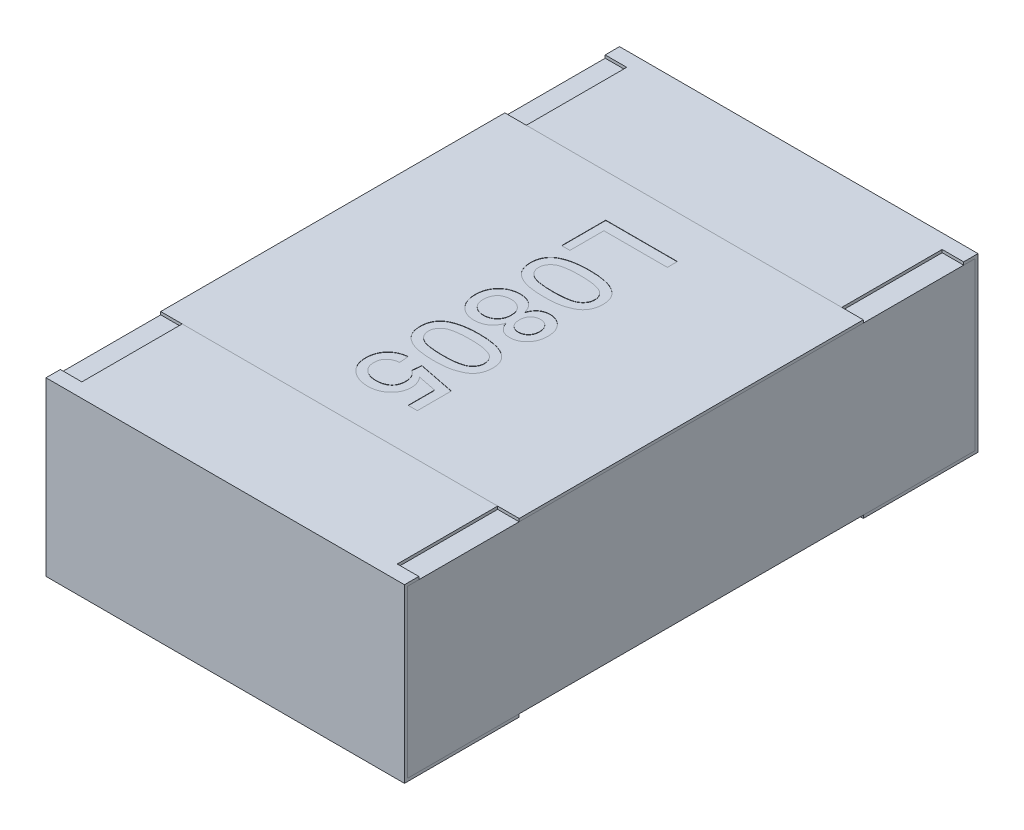
from build123d import *

# Parameters (mm, degrees)
BOSS_EXTRUDE2_DEPTH   = 0.625
BOSS_EXTRUDE2_2_DEPTH = 0.625
BOSS_EXTRUDE3_START   = -0.625
SKETCH5_W             = 1.98
SKETCH5_H             = 0.58
BOSS_EXTRUDE3_DEPTH   = 1.25
SKETCH6_W             = 0.075
SKETCH6_H             = 0.35
CUT_EXTRUDE1_DEPTH    = 0.01
SKETCH7_W             = 1.25
SKETCH7_H             = 1.2
BOSS_EXTRUDE4_DEPTH   = 0.01
TEXT0805_DEPTH        = 0.001


with BuildPart() as part:
    # Sketch4 → Boss-Extrude2 (new body, symmetric)
    with BuildSketch(Plane(origin=(0, 0, 0), x_dir=(0, 0, -1), z_dir=(1, 0, 0))):
        Polygon((-1, 0.3), (-1, -0.3), (-0.6, -0.3), (-0.6, -0.29), (-0.99, -0.29), (-0.99, 0.29), (-0.6, 0.29), (-0.6, 0.3), align=None)
    extrude(amount=BOSS_EXTRUDE2_DEPTH, both=True)


with BuildPart() as body_2:
    # Sketch4 → Boss-Extrude2 2 (new body, symmetric)
    with BuildSketch(Plane(origin=(0, 0, 0), x_dir=(0, 0, -1), z_dir=(1, 0, 0))):
        Polygon((0.6, 0.3), (1, 0.3), (1, -0.3), (0.6, -0.3), (0.6, -0.29), (0.99, -0.29), (0.99, 0.29), (0.6, 0.29), align=None)
    extrude(amount=BOSS_EXTRUDE2_2_DEPTH, both=True)


with BuildPart() as body_3:
    # Sketch5 → Boss-Extrude3 (new body)
    with BuildSketch(Plane(origin=(0, 0, 0), x_dir=(0, 0, -1), z_dir=(1, 0, 0)).offset(BOSS_EXTRUDE3_START)):
        Rectangle(SKETCH5_W, SKETCH5_H)
    extrude(amount=BOSS_EXTRUDE3_DEPTH)


with BuildPart() as cut_extrude1_tool:
    # Sketch6 → Cut-Extrude1 (new body)
    with BuildSketch(Plane(origin=(0, 0.3, 0), x_dir=(1, 0, 0), z_dir=(0, 1, 0))):
        with Locations((-0.5875, 0.775)):
            Rectangle(SKETCH6_W, SKETCH6_H)
        with Locations((0.5875, 0.775)):
            Rectangle(SKETCH6_W, SKETCH6_H)
        with Locations((0.5875, -0.775)):
            Rectangle(SKETCH6_W, SKETCH6_H)
        with Locations((-0.5875, -0.775)):
            Rectangle(SKETCH6_W, SKETCH6_H)
    extrude(amount=-CUT_EXTRUDE1_DEPTH)


with BuildPart() as part_1:
    add(part.part)

    # Cut-Extrude1: cut by cut_extrude1_tool
    add(cut_extrude1_tool.part, mode=Mode.SUBTRACT)


with BuildPart() as body_2_1:
    add(body_2.part)

    # Cut-Extrude1: cut by cut_extrude1_tool
    add(cut_extrude1_tool.part, mode=Mode.SUBTRACT)


with BuildPart() as body_4:
    # Sketch7 → Boss-Extrude4 (new body)
    with BuildSketch(Plane(origin=(0, 0.29, 0), x_dir=(1, 0, 0), z_dir=(0, 1, 0))):
        Rectangle(SKETCH7_W, SKETCH7_H)
    extrude(amount=BOSS_EXTRUDE4_DEPTH)

    # Sketch11 → TEXT0805 (cut)
    with BuildSketch(Plane(origin=(0, 0.3, 0), x_dir=(1, 0, 0), z_dir=(0, 1, 0))):
        Polygon((-0.125, 0.451923077), (0.125, 0.451923077), (0.125, 0.416666667), (-0.096153846, 0.416666667), (-0.096153846, 0.298076923), (-0.125, 0.298076923), align=None)
        with BuildLine():
            add(Edge.make_bspline(
                [(-0.001702724, 0.272435897), (0.001870005, 0.272403606), (0.008867478, 0.27234036), (0.019106037, 0.271948067), (0.028829172, 0.271263154), (0.038028443, 0.270240773), (0.0467246, 0.269030064), (0.05490528, 0.267456198), (0.062588678, 0.265685164), (0.069767331, 0.263560961), (0.076501073, 0.261224714), (0.082785669, 0.25858275), (0.088583945, 0.255584058), (0.094053366, 0.252499041), (0.098937729, 0.248907292), (0.103546409, 0.245264826), (0.107616333, 0.241199109), (0.111280719, 0.236903509), (0.114513306, 0.232306834), (0.117302904, 0.227435485), (0.119765846, 0.222307654), (0.121619965, 0.216825758), (0.12313146, 0.211103562), (0.124243336, 0.205097029), (0.124898824, 0.198799537), (0.124965894, 0.194496087), (0.125, 0.192307692)],
                knots=[0, 0, 0, 0, 1.0718e-05, 2.0992e-05, 3.0733e-05, 3.9952e-05, 4.8756e-05, 5.7065e-05, 6.4937e-05, 7.2401e-05, 7.9512e-05, 8.6312e-05, 9.2829e-05, 9.9091e-05, 0.000105122, 0.000110996, 0.000116698, 0.000122347, 0.000127918, 0.000133528, 0.000139173, 0.000144954, 0.000150858, 0.000156918, 0.000163262, 0.000169825, 0.000169825, 0.000169825, 0.000169825], degree=3))
            add(Edge.make_bspline(
                [(0.125, 0.192307692), (0.124905525, 0.18909709), (0.124719924, 0.182789734), (0.123208745, 0.173579982), (0.120617247, 0.164904112), (0.11714849, 0.156763482), (0.11266138, 0.149334117), (0.107346921, 0.142617281), (0.100982609, 0.136884361), (0.0937773, 0.131945986), (0.08571669, 0.12771133), (0.076876688, 0.123923256), (0.067219821, 0.120526895), (0.05860006, 0.118040907), (0.051146572, 0.116298009), (0.044987523, 0.115236883), (0.038362276, 0.114257157), (0.031254967, 0.113562714), (0.023698813, 0.112856061), (0.015660865, 0.112507178), (0.007146582, 0.112240929), (0.001302343, 0.112200352), (-0.001702724, 0.112179487)],
                knots=[0, 0, 0, 0, 9.628e-06, 1.8915e-05, 2.79e-05, 3.6738e-05, 4.5387e-05, 5.3865e-05, 6.2337e-05, 7.0978e-05, 8.0007e-05, 8.9608e-05, 9.9808e-05, 0.000110698, 0.000116505, 0.000122762, 0.000129441, 0.000136592, 0.000144182, 0.000152205, 0.000160722, 0.000169737, 0.000169737, 0.000169737, 0.000169737], degree=3))
            add(Edge.make_bspline(
                [(-0.001702724, 0.112179487), (-0.0052587, 0.112212202), (-0.012205999, 0.112276116), (-0.022362073, 0.112660426), (-0.032013225, 0.113377706), (-0.041171226, 0.114302026), (-0.049844567, 0.115546506), (-0.058012023, 0.117101962), (-0.065683611, 0.118898516), (-0.072867068, 0.120931564), (-0.079572281, 0.123296867), (-0.085831338, 0.125964616), (-0.09170557, 0.128825232), (-0.097085574, 0.132069947), (-0.10206041, 0.135525761), (-0.106645739, 0.139224961), (-0.110776391, 0.143244169), (-0.114428737, 0.147579866), (-0.117719455, 0.152143727), (-0.120534419, 0.157027735), (-0.122882805, 0.162220464), (-0.124845559, 0.167675633), (-0.126337213, 0.173429452), (-0.127444725, 0.17945194), (-0.12810623, 0.185782388), (-0.128171707, 0.190102581), (-0.128205128, 0.192307692)],
                knots=[0, 0, 0, 0, 1.0668e-05, 2.0842e-05, 3.0483e-05, 3.9697e-05, 4.8451e-05, 5.676e-05, 6.4632e-05, 7.2082e-05, 7.9146e-05, 8.5946e-05, 9.2485e-05, 9.8729e-05, 0.000104773, 0.000110647, 0.000116384, 0.000122033, 0.000127634, 0.000133243, 0.000138913, 0.00014471, 0.000150614, 0.000156724, 0.000163067, 0.000169681, 0.000169681, 0.000169681, 0.000169681], degree=3))
            add(Edge.make_bspline(
                [(-0.128205128, 0.192307692), (-0.12812266, 0.195198784), (-0.127961869, 0.200835617), (-0.126869393, 0.209067795), (-0.124946585, 0.216794134), (-0.122367828, 0.2240798), (-0.118918593, 0.2308429), (-0.114721924, 0.237115726), (-0.109875462, 0.243024326), (-0.106051714, 0.246425675), (-0.104116587, 0.248147035)],
                knots=[0, 0, 0, 0, 8.673e-06, 1.691e-05, 2.4854e-05, 3.2521e-05, 4.0047e-05, 4.7561e-05, 5.5134e-05, 6.2893e-05, 6.2893e-05, 6.2893e-05, 6.2893e-05], degree=3))
            add(Edge.make_bspline(
                [(-0.104116587, 0.248147035), (-0.101258496, 0.25012836), (-0.095364991, 0.254213937), (-0.085316019, 0.258995751), (-0.074253512, 0.263261213), (-0.061960424, 0.266608819), (-0.048534594, 0.269230829), (-0.03394968, 0.271124575), (-0.01821198, 0.272196249), (-0.007330039, 0.272354211), (-0.001702724, 0.272435897)],
                knots=[0, 0, 0, 0, 1.0418e-05, 2.1482e-05, 3.3275e-05, 4.596e-05, 5.9642e-05, 7.4289e-05, 9.0053e-05, 0.000106934, 0.000106934, 0.000106934, 0.000106934], degree=3))
        make_face()
        with BuildLine():
            add(Edge.make_bspline(
                [(-0.001602564, 0.240384615), (-0.006410973, 0.240352791), (-0.015615332, 0.240291872), (-0.028765347, 0.239655418), (-0.040628456, 0.238559787), (-0.051188232, 0.237111292), (-0.060458961, 0.235198693), (-0.068417018, 0.232797198), (-0.075157918, 0.230090142), (-0.080598111, 0.226740211), (-0.085032663, 0.223072407), (-0.088846521, 0.21928565), (-0.092088212, 0.215290851), (-0.094791122, 0.211114075), (-0.096837588, 0.206690516), (-0.098320871, 0.202068546), (-0.099174477, 0.197247159), (-0.099297124, 0.193963576), (-0.099358974, 0.192307692)],
                knots=[0, 0, 0, 0, 1.4424e-05, 2.7612e-05, 3.9482e-05, 5.0155e-05, 5.9574e-05, 6.7844e-05, 7.5071e-05, 8.1298e-05, 8.6922e-05, 9.2305e-05, 9.7396e-05, 0.000102328, 0.00010719, 0.000111973, 0.000116856, 0.000121823, 0.000121823, 0.000121823, 0.000121823], degree=3))
            add(Edge.make_bspline(
                [(-0.099358974, 0.192307692), (-0.099295773, 0.190652224), (-0.099170446, 0.187369462), (-0.098335662, 0.182536935), (-0.096776021, 0.177932948), (-0.094736783, 0.173515985), (-0.092095481, 0.169308851), (-0.088841545, 0.165333672), (-0.085029952, 0.161526967), (-0.080543857, 0.157875638), (-0.075078511, 0.154551229), (-0.068343103, 0.151793392), (-0.060371109, 0.149429323), (-0.051105103, 0.147506229), (-0.040562022, 0.146051759), (-0.028731817, 0.144962753), (-0.015598722, 0.144322039), (-0.006410995, 0.144262125), (-0.001602564, 0.144230769)],
                knots=[0, 0, 0, 0, 4.967e-06, 9.85e-06, 1.4648e-05, 1.951e-05, 2.4415e-05, 2.9507e-05, 3.4889e-05, 4.0552e-05, 4.6822e-05, 5.4003e-05, 6.232e-05, 7.174e-05, 8.2363e-05, 9.4234e-05, 0.000107371, 0.000121795, 0.000121795, 0.000121795, 0.000121795], degree=3))
            add(Edge.make_bspline(
                [(-0.001602564, 0.144230769), (0.003105819, 0.144261121), (0.012126904, 0.144319273), (0.025023578, 0.144976517), (0.036687586, 0.146006453), (0.047129588, 0.147415317), (0.05633854, 0.149287459), (0.064333139, 0.151558832), (0.071099127, 0.154263308), (0.07669585, 0.15748571), (0.08131576, 0.161058606), (0.085236709, 0.164854717), (0.088672768, 0.168800579), (0.091363273, 0.173121683), (0.093569875, 0.177634331), (0.095047046, 0.182435261), (0.095995083, 0.187462483), (0.096100151, 0.190900998), (0.096153846, 0.192658253)],
                knots=[0, 0, 0, 0, 1.4124e-05, 2.7061e-05, 3.8727e-05, 4.9245e-05, 5.8654e-05, 6.6895e-05, 7.4149e-05, 8.0454e-05, 8.6204e-05, 9.1623e-05, 9.681e-05, 0.000101853, 0.000106849, 0.000111838, 0.000116877, 0.000122144, 0.000122144, 0.000122144, 0.000122144], degree=3))
            add(Edge.make_bspline(
                [(0.096153846, 0.192658253), (0.096110388, 0.194314033), (0.096024696, 0.197579017), (0.095206757, 0.202359382), (0.093838982, 0.206889678), (0.091986197, 0.211221807), (0.089492715, 0.21524762), (0.086581397, 0.219126771), (0.083034282, 0.222677576), (0.080382513, 0.224817259), (0.079026442, 0.225911458)],
                knots=[0, 0, 0, 0, 4.964e-06, 9.789e-06, 1.4495e-05, 1.9137e-05, 2.3878e-05, 2.8666e-05, 3.3659e-05, 3.8885e-05, 3.8885e-05, 3.8885e-05, 3.8885e-05], degree=3))
            add(Edge.make_bspline(
                [(0.079026442, 0.225911458), (0.077034794, 0.227102708), (0.072828852, 0.229618375), (0.065518751, 0.232433261), (0.057164697, 0.234919819), (0.047638157, 0.236967082), (0.036955473, 0.238448132), (0.02512905, 0.239617364), (0.012142378, 0.240224737), (0.003105492, 0.240329852), (-0.001602564, 0.240384615)],
                knots=[0, 0, 0, 0, 6.951e-06, 1.4679e-05, 2.3409e-05, 3.3095e-05, 4.3874e-05, 5.5749e-05, 6.8736e-05, 8.2861e-05, 8.2861e-05, 8.2861e-05, 8.2861e-05], degree=3))
        make_face(mode=Mode.SUBTRACT)
        with BuildLine():
            add(Edge.make_bspline(
                [(0.012119391, 0.032652244), (0.01269909, 0.034213507), (0.013835412, 0.037273885), (0.015864898, 0.041621309), (0.017988986, 0.045696533), (0.020361222, 0.049424993), (0.022920717, 0.052827936), (0.025628265, 0.055961759), (0.028525648, 0.058763651), (0.032625581, 0.062056033), (0.038234929, 0.065438113), (0.045564597, 0.068458329), (0.053575195, 0.070164789), (0.059103354, 0.070394547), (0.061949119, 0.070512821)],
                knots=[0, 0, 0, 0, 4.994e-06, 9.79e-06, 1.4382e-05, 1.8773e-05, 2.3029e-05, 2.7147e-05, 3.1184e-05, 3.5103e-05, 4.2902e-05, 5.0741e-05, 5.8786e-05, 6.7321e-05, 6.7321e-05, 6.7321e-05, 6.7321e-05], degree=3))
            add(Edge.make_bspline(
                [(0.061949119, 0.070512821), (0.064139193, 0.070457699), (0.068438378, 0.070349494), (0.074747821, 0.069418445), (0.080789537, 0.06791792), (0.08657372, 0.065818866), (0.092056945, 0.063073452), (0.097320111, 0.059811162), (0.102279042, 0.055883595), (0.106898797, 0.051381865), (0.111182055, 0.046446159), (0.114879575, 0.041028615), (0.118009057, 0.035216847), (0.120563589, 0.029022334), (0.122583213, 0.022436852), (0.123954826, 0.015437091), (0.124828309, 0.00805156), (0.124941878, 0.002990667), (0.125, 0.000400641)],
                knots=[0, 0, 0, 0, 6.567e-06, 1.2892e-05, 1.9087e-05, 2.5218e-05, 3.131e-05, 3.7452e-05, 4.3764e-05, 5.0245e-05, 5.6779e-05, 6.3336e-05, 6.9879e-05, 7.6547e-05, 8.3407e-05, 9.0508e-05, 9.7918e-05, 0.000105687, 0.000105687, 0.000105687, 0.000105687], degree=3))
            add(Edge.make_bspline(
                [(0.125, 0.000400641), (0.124941265, -0.002205875), (0.124826857, -0.007283075), (0.123965422, -0.014708029), (0.122521604, -0.021751301), (0.120473189, -0.028408745), (0.117854168, -0.034690855), (0.114635047, -0.040556354), (0.110868919, -0.046065621), (0.106510873, -0.051077843), (0.101779453, -0.055638367), (0.0967105, -0.05958963), (0.091422295, -0.062978503), (0.085882711, -0.065778898), (0.080028668, -0.06785064), (0.073970458, -0.069429773), (0.067636097, -0.070345743), (0.063337574, -0.070456433), (0.061147837, -0.070512821)],
                knots=[0, 0, 0, 0, 7.818e-06, 1.5229e-05, 2.2389e-05, 2.9359e-05, 3.6093e-05, 4.2772e-05, 4.9398e-05, 5.6074e-05, 6.2662e-05, 6.9083e-05, 7.5321e-05, 8.148e-05, 8.7659e-05, 9.3914e-05, 0.000100239, 0.000106806, 0.000106806, 0.000106806, 0.000106806], degree=3))
            add(Edge.make_bspline(
                [(0.061147837, -0.070512821), (0.058399838, -0.070420844), (0.05301153, -0.070240494), (0.045240017, -0.068415514), (0.038009242, -0.065546561), (0.031360465, -0.061497692), (0.025401741, -0.05620734), (0.020153187, -0.049738869), (0.015599968, -0.042093945), (0.013310814, -0.036411195), (0.012119391, -0.033453526)],
                knots=[0, 0, 0, 0, 8.232e-06, 1.6141e-05, 2.3804e-05, 3.1491e-05, 3.9368e-05, 4.7588e-05, 5.6392e-05, 6.5947e-05, 6.5947e-05, 6.5947e-05, 6.5947e-05], degree=3))
            add(Edge.make_bspline(
                [(0.012119391, -0.033453526), (0.011486132, -0.035320084), (0.010245219, -0.038977728), (0.007827392, -0.044145372), (0.005245987, -0.049010217), (0.002377789, -0.053568019), (-0.000811827, -0.057753297), (-0.004308014, -0.061594944), (-0.008060229, -0.065116703), (-0.012130537, -0.068264043), (-0.016426954, -0.071077117), (-0.020965154, -0.07347648), (-0.025661352, -0.075544387), (-0.030598138, -0.077191573), (-0.035704671, -0.07856952), (-0.041059344, -0.079434802), (-0.046578672, -0.080008825), (-0.050329008, -0.080087998), (-0.052233574, -0.080128205)],
                knots=[0, 0, 0, 0, 5.909e-06, 1.1579e-05, 1.709e-05, 2.2426e-05, 2.7714e-05, 3.2855e-05, 3.7993e-05, 4.3132e-05, 4.8271e-05, 5.3379e-05, 5.8515e-05, 6.3646e-05, 6.8979e-05, 7.4363e-05, 7.99e-05, 8.5612e-05, 8.5612e-05, 8.5612e-05, 8.5612e-05], degree=3))
            add(Edge.make_bspline(
                [(-0.052233574, -0.080128205), (-0.054858381, -0.080064515), (-0.060029453, -0.079939041), (-0.067619915, -0.078836425), (-0.074911834, -0.077168493), (-0.081873258, -0.074735104), (-0.088513354, -0.071631881), (-0.094798012, -0.067780462), (-0.100791216, -0.063297747), (-0.106432415, -0.058183936), (-0.111499298, -0.052431555), (-0.116010417, -0.046254834), (-0.119770796, -0.039586089), (-0.122887601, -0.032511172), (-0.125302275, -0.02499214), (-0.126993274, -0.017039771), (-0.128000136, -0.008656403), (-0.128135882, -0.002924128), (-0.128205128, 0)],
                knots=[0, 0, 0, 0, 7.87e-06, 1.5505e-05, 2.2964e-05, 3.0281e-05, 3.7584e-05, 4.4911e-05, 5.2353e-05, 6.001e-05, 6.7708e-05, 7.5311e-05, 8.2914e-05, 9.0628e-05, 9.8468e-05, 0.000106562, 0.000114985, 0.000123756, 0.000123756, 0.000123756, 0.000123756], degree=3))
            add(Edge.make_bspline(
                [(-0.128205128, 0), (-0.128134392, 0.002923837), (-0.127995726, 0.008655543), (-0.127009414, 0.017046541), (-0.125241883, 0.024987638), (-0.122824315, 0.032496516), (-0.119793471, 0.039615029), (-0.11594243, 0.046233962), (-0.11147352, 0.052449666), (-0.10631221, 0.058118942), (-0.100673887, 0.063260362), (-0.094654208, 0.067801512), (-0.088267465, 0.071613337), (-0.081548187, 0.074761024), (-0.074471787, 0.077156531), (-0.067069103, 0.078838687), (-0.059344627, 0.079943152), (-0.054073749, 0.080065652), (-0.051382212, 0.080128205)],
                knots=[0, 0, 0, 0, 8.771e-06, 1.7194e-05, 2.5299e-05, 3.3138e-05, 4.0832e-05, 4.846e-05, 5.6063e-05, 6.3758e-05, 7.1415e-05, 7.8927e-05, 8.6339e-05, 9.3688e-05, 0.000101147, 0.000108703, 0.000116437, 0.000124508, 0.000124508, 0.000124508, 0.000124508], degree=3))
            add(Edge.make_bspline(
                [(-0.051382212, 0.080128205), (-0.049378145, 0.080084759), (-0.045445821, 0.07999951), (-0.039678396, 0.079477979), (-0.034180584, 0.07844092), (-0.028923938, 0.077097763), (-0.023874605, 0.075416624), (-0.019130745, 0.073246408), (-0.014623334, 0.070719071), (-0.010375603, 0.067828837), (-0.006424966, 0.064555468), (-0.002731152, 0.06100755), (0.00055556, 0.057062039), (0.003608555, 0.052869102), (0.006185309, 0.048242245), (0.008551026, 0.043358849), (0.010568264, 0.038133473), (0.01159717, 0.034497618), (0.012119391, 0.032652244)],
                knots=[0, 0, 0, 0, 6.013e-06, 1.1798e-05, 1.7348e-05, 2.2778e-05, 2.8067e-05, 3.329e-05, 3.8402e-05, 4.3555e-05, 4.8679e-05, 5.3779e-05, 5.8896e-05, 6.4065e-05, 6.9314e-05, 7.4757e-05, 8.0337e-05, 8.6089e-05, 8.6089e-05, 8.6089e-05, 8.6089e-05], degree=3))
        make_face()
        with BuildLine():
            add(Edge.make_bspline(
                [(0.061798878, 0.038461538), (0.060495731, 0.038432701), (0.057948075, 0.038376323), (0.054219589, 0.037935241), (0.050688509, 0.037113289), (0.047327484, 0.036026113), (0.044148049, 0.034600152), (0.041119708, 0.032911071), (0.038315435, 0.030835996), (0.035718639, 0.028485246), (0.03333419, 0.025876827), (0.031278449, 0.022943987), (0.029512989, 0.01974209), (0.028144416, 0.016241125), (0.026930821, 0.01253058), (0.02625274, 0.008481155), (0.025701414, 0.004188403), (0.02566149, 0.001220708), (0.025641026, -0.000300481)],
                knots=[0, 0, 0, 0, 3.909e-06, 7.642e-06, 1.1238e-05, 1.477e-05, 1.8223e-05, 2.1676e-05, 2.5152e-05, 2.8662e-05, 3.2173e-05, 3.573e-05, 3.9383e-05, 4.3112e-05, 4.6993e-05, 5.1069e-05, 5.5405e-05, 5.9965e-05, 5.9965e-05, 5.9965e-05, 5.9965e-05], degree=3))
            add(Edge.make_bspline(
                [(0.025641026, -0.000300481), (0.025662169, -0.001788126), (0.025703396, -0.004688952), (0.026244552, -0.008884533), (0.026962031, -0.012851597), (0.02807298, -0.016536028), (0.029449425, -0.019986946), (0.03126392, -0.02309458), (0.033226338, -0.02604389), (0.036371177, -0.029452843), (0.040796311, -0.033063505), (0.046787919, -0.036207655), (0.053365823, -0.038158949), (0.057945699, -0.038358904), (0.060296474, -0.038461538)],
                knots=[0, 0, 0, 0, 4.46e-06, 8.696e-06, 1.2674e-05, 1.654e-05, 2.0223e-05, 2.3789e-05, 2.7317e-05, 3.0827e-05, 3.7663e-05, 4.4339e-05, 5.1011e-05, 5.8048e-05, 5.8048e-05, 5.8048e-05, 5.8048e-05], degree=3))
            add(Edge.make_bspline(
                [(0.060296474, -0.038461538), (0.062729605, -0.038338162), (0.067490611, -0.038096745), (0.074325249, -0.036146933), (0.080515391, -0.032864253), (0.085035964, -0.029114247), (0.088310852, -0.025643497), (0.090395538, -0.022674094), (0.09216979, -0.019481975), (0.093618706, -0.01605499), (0.094787272, -0.012388184), (0.095553907, -0.008471624), (0.096091576, -0.004321767), (0.096132653, -0.001470901), (0.096153846, 0)],
                knots=[0, 0, 0, 0, 7.291e-06, 1.4266e-05, 2.1121e-05, 2.8168e-05, 3.1783e-05, 3.541e-05, 3.9019e-05, 4.2722e-05, 4.6555e-05, 5.0542e-05, 5.4679e-05, 5.9089e-05, 5.9089e-05, 5.9089e-05, 5.9089e-05], degree=3))
            add(Edge.make_bspline(
                [(0.096153846, 0), (0.096133333, 0.001471061), (0.096093343, 0.004338823), (0.095539611, 0.008515788), (0.094843795, 0.012469294), (0.093728417, 0.016163856), (0.092266626, 0.019580619), (0.090509244, 0.022755873), (0.088446204, 0.025681252), (0.085326174, 0.029176213), (0.080947968, 0.032885862), (0.075014807, 0.036103646), (0.06856883, 0.0380999), (0.06408348, 0.038339499), (0.061798878, 0.038461538)],
                knots=[0, 0, 0, 0, 4.41e-06, 8.596e-06, 1.2623e-05, 1.6442e-05, 2.0144e-05, 2.3753e-05, 2.731e-05, 3.0858e-05, 3.7789e-05, 4.44e-05, 5.0991e-05, 5.7833e-05, 5.7833e-05, 5.7833e-05, 5.7833e-05], degree=3))
        make_face(mode=Mode.SUBTRACT)
        with BuildLine():
            add(Edge.make_bspline(
                [(-0.05078125, 0.048076923), (-0.052837969, 0.048021843), (-0.056956823, 0.047911538), (-0.063071804, 0.04693271), (-0.069088196, 0.045298854), (-0.074959239, 0.043103235), (-0.080524259, 0.040136933), (-0.085452178, 0.036168296), (-0.089669433, 0.031241343), (-0.09313775, 0.025528781), (-0.095914827, 0.019344715), (-0.097863459, 0.012910483), (-0.099131517, 0.006376627), (-0.099283147, 0.001958861), (-0.099358974, -0.000250401)],
                knots=[0, 0, 0, 0, 6.167e-06, 1.2351e-05, 1.8522e-05, 2.4846e-05, 3.1121e-05, 3.7355e-05, 4.371e-05, 5.0479e-05, 5.7338e-05, 6.3992e-05, 7.0612e-05, 7.7235e-05, 7.7235e-05, 7.7235e-05, 7.7235e-05], degree=3))
            add(Edge.make_bspline(
                [(-0.099358974, -0.000250401), (-0.099328114, -0.002072253), (-0.09926816, -0.005611593), (-0.098583058, -0.010770843), (-0.097543536, -0.015632023), (-0.096118179, -0.020217402), (-0.094168202, -0.024459502), (-0.091889083, -0.028427347), (-0.089134664, -0.032080563), (-0.085990915, -0.035417317), (-0.082514314, -0.038406616), (-0.078760273, -0.040958945), (-0.074856366, -0.043213189), (-0.070647139, -0.044940958), (-0.066247417, -0.046357493), (-0.061617296, -0.047348416), (-0.056774438, -0.047969439), (-0.053470829, -0.048040576), (-0.051782853, -0.048076923)],
                knots=[0, 0, 0, 0, 5.462e-06, 1.0612e-05, 1.5582e-05, 2.0365e-05, 2.4982e-05, 2.9561e-05, 3.4068e-05, 3.8674e-05, 4.3291e-05, 4.7792e-05, 5.2276e-05, 5.6788e-05, 6.1412e-05, 6.6127e-05, 7.0972e-05, 7.6034e-05, 7.6034e-05, 7.6034e-05, 7.6034e-05], degree=3))
            add(Edge.make_bspline(
                [(-0.051782853, -0.048076923), (-0.050061743, -0.048039402), (-0.046692086, -0.047965941), (-0.041742935, -0.047360491), (-0.037031308, -0.046312532), (-0.032552602, -0.044832996), (-0.028263925, -0.043055681), (-0.02422898, -0.04078657), (-0.020483035, -0.038041587), (-0.016921285, -0.035022182), (-0.013696197, -0.031607817), (-0.01091531, -0.027836607), (-0.008459253, -0.023828866), (-0.006575265, -0.019463139), (-0.005066143, -0.014835669), (-0.003969594, -0.009924453), (-0.003299302, -0.004709473), (-0.003237126, -0.001137235), (-0.003205128, 0.000701122)],
                knots=[0, 0, 0, 0, 5.162e-06, 1.0107e-05, 1.493e-05, 1.9618e-05, 2.4241e-05, 2.8838e-05, 3.3466e-05, 3.8154e-05, 4.283e-05, 4.7518e-05, 5.219e-05, 5.6899e-05, 6.1745e-05, 6.6775e-05, 7.1974e-05, 7.7486e-05, 7.7486e-05, 7.7486e-05, 7.7486e-05], degree=3))
            add(Edge.make_bspline(
                [(-0.003205128, 0.000701122), (-0.003237499, 0.002489532), (-0.003300957, 0.005995372), (-0.003974271, 0.011088814), (-0.005012193, 0.015909154), (-0.006512687, 0.02040685), (-0.00843275, 0.0246279), (-0.010797253, 0.028533758), (-0.013563742, 0.032180505), (-0.016770954, 0.035459464), (-0.02028219, 0.038394917), (-0.023969655, 0.041032572), (-0.027939232, 0.043183301), (-0.032078327, 0.045013797), (-0.036478589, 0.046337504), (-0.04104453, 0.047354304), (-0.045840111, 0.04796796), (-0.04911013, 0.048040071), (-0.05078125, 0.048076923)],
                knots=[0, 0, 0, 0, 5.362e-06, 1.0512e-05, 1.5384e-05, 2.0135e-05, 2.4707e-05, 2.9267e-05, 3.3805e-05, 3.8409e-05, 4.2994e-05, 4.7523e-05, 5.1984e-05, 5.6514e-05, 6.1076e-05, 6.5742e-05, 7.0538e-05, 7.555e-05, 7.555e-05, 7.555e-05, 7.555e-05], degree=3))
        make_face(mode=Mode.SUBTRACT)
        with BuildLine():
            add(Edge.make_bspline(
                [(-0.001702724, -0.112179487), (0.001870005, -0.112211779), (0.008867478, -0.112275025), (0.019106037, -0.112667317), (0.028829172, -0.113352231), (0.038028443, -0.114374612), (0.0467246, -0.11558532), (0.05490528, -0.117159187), (0.062588678, -0.118930221), (0.069767331, -0.121054424), (0.076501073, -0.123390671), (0.082785669, -0.126032635), (0.088583945, -0.129031327), (0.094053366, -0.132116344), (0.098937729, -0.135708093), (0.103546409, -0.139350558), (0.107616333, -0.143416275), (0.111280719, -0.147711875), (0.114513306, -0.152308551), (0.117302904, -0.157179899), (0.119765846, -0.162307731), (0.121619965, -0.167789626), (0.12313146, -0.173511823), (0.124243336, -0.179518356), (0.124898824, -0.185815847), (0.124965894, -0.190119298), (0.125, -0.192307692)],
                knots=[0, 0, 0, 0, 1.0718e-05, 2.0992e-05, 3.0733e-05, 3.9952e-05, 4.8756e-05, 5.7065e-05, 6.4937e-05, 7.2401e-05, 7.9512e-05, 8.6312e-05, 9.2829e-05, 9.9091e-05, 0.000105122, 0.000110996, 0.000116698, 0.000122347, 0.000127918, 0.000133528, 0.000139173, 0.000144954, 0.000150858, 0.000156918, 0.000163262, 0.000169825, 0.000169825, 0.000169825, 0.000169825], degree=3))
            add(Edge.make_bspline(
                [(0.125, -0.192307692), (0.124905525, -0.195518294), (0.124719924, -0.201825651), (0.123208745, -0.211035403), (0.120617247, -0.219711273), (0.11714849, -0.227851903), (0.11266138, -0.235281267), (0.107346921, -0.241998104), (0.100982609, -0.247731023), (0.0937773, -0.252669398), (0.08571669, -0.256904055), (0.076876688, -0.260692129), (0.067219821, -0.264088489), (0.05860006, -0.266574478), (0.051146572, -0.268317376), (0.044987523, -0.269378501), (0.038362276, -0.270358228), (0.031254967, -0.271052671), (0.023698813, -0.271759323), (0.015660865, -0.272108206), (0.007146582, -0.272374456), (0.001302343, -0.272415033), (-0.001702724, -0.272435897)],
                knots=[0, 0, 0, 0, 9.628e-06, 1.8915e-05, 2.79e-05, 3.6738e-05, 4.5387e-05, 5.3865e-05, 6.2337e-05, 7.0978e-05, 8.0007e-05, 8.9608e-05, 9.9808e-05, 0.000110698, 0.000116505, 0.000122762, 0.000129441, 0.000136592, 0.000144182, 0.000152205, 0.000160722, 0.000169737, 0.000169737, 0.000169737, 0.000169737], degree=3))
            add(Edge.make_bspline(
                [(-0.001702724, -0.272435897), (-0.0052587, -0.272403183), (-0.012205999, -0.272339269), (-0.022362073, -0.271954958), (-0.032013225, -0.271237679), (-0.041171226, -0.270313359), (-0.049844567, -0.269068879), (-0.058012023, -0.267513423), (-0.065683611, -0.265716868), (-0.072867068, -0.263683821), (-0.079572281, -0.261318518), (-0.085831338, -0.258650768), (-0.09170557, -0.255790153), (-0.097085574, -0.252545438), (-0.10206041, -0.249089624), (-0.106645739, -0.245390424), (-0.110776391, -0.241371216), (-0.114428737, -0.237035519), (-0.117719455, -0.232471658), (-0.120534419, -0.22758765), (-0.122882805, -0.222394921), (-0.124845559, -0.216939752), (-0.126337213, -0.211185933), (-0.127444725, -0.205163445), (-0.12810623, -0.198832996), (-0.128171707, -0.194512803), (-0.128205128, -0.192307692)],
                knots=[0, 0, 0, 0, 1.0668e-05, 2.0842e-05, 3.0483e-05, 3.9697e-05, 4.8451e-05, 5.676e-05, 6.4632e-05, 7.2082e-05, 7.9146e-05, 8.5946e-05, 9.2485e-05, 9.8729e-05, 0.000104773, 0.000110647, 0.000116384, 0.000122033, 0.000127634, 0.000133243, 0.000138913, 0.00014471, 0.000150614, 0.000156724, 0.000163067, 0.000169681, 0.000169681, 0.000169681, 0.000169681], degree=3))
            add(Edge.make_bspline(
                [(-0.128205128, -0.192307692), (-0.12812266, -0.189416601), (-0.127961869, -0.183779768), (-0.126869393, -0.17554759), (-0.124946585, -0.167821251), (-0.122367828, -0.160535585), (-0.118918593, -0.153772484), (-0.114721924, -0.147499658), (-0.109875462, -0.141591059), (-0.106051714, -0.138189709), (-0.104116587, -0.136468349)],
                knots=[0, 0, 0, 0, 8.673e-06, 1.691e-05, 2.4854e-05, 3.2521e-05, 4.0047e-05, 4.7561e-05, 5.5134e-05, 6.2893e-05, 6.2893e-05, 6.2893e-05, 6.2893e-05], degree=3))
            add(Edge.make_bspline(
                [(-0.104116587, -0.136468349), (-0.101258496, -0.134487024), (-0.095364991, -0.130401447), (-0.085316019, -0.125619634), (-0.074253512, -0.121354171), (-0.061960424, -0.118006565), (-0.048534594, -0.115384555), (-0.03394968, -0.11349081), (-0.01821198, -0.112419136), (-0.007330039, -0.112261173), (-0.001702724, -0.112179487)],
                knots=[0, 0, 0, 0, 1.0418e-05, 2.1482e-05, 3.3275e-05, 4.596e-05, 5.9642e-05, 7.4289e-05, 9.0053e-05, 0.000106934, 0.000106934, 0.000106934, 0.000106934], degree=3))
        make_face()
        with BuildLine():
            add(Edge.make_bspline(
                [(-0.001602564, -0.144230769), (-0.006410973, -0.144262594), (-0.015615332, -0.144323512), (-0.028765347, -0.144959967), (-0.040628456, -0.146055597), (-0.051188232, -0.147504092), (-0.060458961, -0.149416692), (-0.068417018, -0.151818187), (-0.075157918, -0.154525243), (-0.080598111, -0.157875174), (-0.085032663, -0.161542978), (-0.088846521, -0.165329735), (-0.092088212, -0.169324534), (-0.094791122, -0.17350131), (-0.096837588, -0.177924868), (-0.098320871, -0.182546838), (-0.099174477, -0.187368225), (-0.099297124, -0.190651809), (-0.099358974, -0.192307692)],
                knots=[0, 0, 0, 0, 1.4424e-05, 2.7612e-05, 3.9482e-05, 5.0155e-05, 5.9574e-05, 6.7844e-05, 7.5071e-05, 8.1298e-05, 8.6922e-05, 9.2305e-05, 9.7396e-05, 0.000102328, 0.00010719, 0.000111973, 0.000116856, 0.000121823, 0.000121823, 0.000121823, 0.000121823], degree=3))
            add(Edge.make_bspline(
                [(-0.099358974, -0.192307692), (-0.099295773, -0.193963161), (-0.099170446, -0.197245922), (-0.098335662, -0.20207845), (-0.096776021, -0.206682437), (-0.094736783, -0.211099399), (-0.092095481, -0.215306533), (-0.088841545, -0.219281713), (-0.085029952, -0.223088418), (-0.080543857, -0.226739746), (-0.075078511, -0.230064155), (-0.068343103, -0.232821992), (-0.060371109, -0.235186062), (-0.051105103, -0.237109156), (-0.040562022, -0.238563626), (-0.028731817, -0.239652632), (-0.015598722, -0.240293346), (-0.006410995, -0.240353259), (-0.001602564, -0.240384615)],
                knots=[0, 0, 0, 0, 4.967e-06, 9.85e-06, 1.4648e-05, 1.951e-05, 2.4415e-05, 2.9507e-05, 3.4889e-05, 4.0552e-05, 4.6822e-05, 5.4003e-05, 6.232e-05, 7.174e-05, 8.2363e-05, 9.4234e-05, 0.000107371, 0.000121795, 0.000121795, 0.000121795, 0.000121795], degree=3))
            add(Edge.make_bspline(
                [(-0.001602564, -0.240384615), (0.003105819, -0.240354264), (0.012126904, -0.240296111), (0.025023578, -0.239638867), (0.036687586, -0.238608932), (0.047129588, -0.237200068), (0.05633854, -0.235327926), (0.064333139, -0.233056553), (0.071099127, -0.230352077), (0.07669585, -0.227129675), (0.08131576, -0.223556778), (0.085236709, -0.219760668), (0.088672768, -0.215814806), (0.091363273, -0.211493702), (0.093569875, -0.206981053), (0.095047046, -0.202180123), (0.095995083, -0.197152902), (0.096100151, -0.193714386), (0.096153846, -0.191957131)],
                knots=[0, 0, 0, 0, 1.4124e-05, 2.7061e-05, 3.8727e-05, 4.9245e-05, 5.8654e-05, 6.6895e-05, 7.4149e-05, 8.0454e-05, 8.6204e-05, 9.1623e-05, 9.681e-05, 0.000101853, 0.000106849, 0.000111838, 0.000116877, 0.000122144, 0.000122144, 0.000122144, 0.000122144], degree=3))
            add(Edge.make_bspline(
                [(0.096153846, -0.191957131), (0.096110388, -0.190301352), (0.096024696, -0.187036367), (0.095206757, -0.182256002), (0.093838982, -0.177725706), (0.091986197, -0.173393577), (0.089492715, -0.169367764), (0.086581397, -0.165488613), (0.083034282, -0.161937809), (0.080382513, -0.159798126), (0.079026442, -0.158703926)],
                knots=[0, 0, 0, 0, 4.964e-06, 9.789e-06, 1.4495e-05, 1.9137e-05, 2.3878e-05, 2.8666e-05, 3.3659e-05, 3.8885e-05, 3.8885e-05, 3.8885e-05, 3.8885e-05], degree=3))
            add(Edge.make_bspline(
                [(0.079026442, -0.158703926), (0.077034794, -0.157512677), (0.072828852, -0.15499701), (0.065518751, -0.152182124), (0.057164697, -0.149695565), (0.047638157, -0.147648303), (0.036955473, -0.146167252), (0.02512905, -0.14499802), (0.012142378, -0.144390648), (0.003105492, -0.144285532), (-0.001602564, -0.144230769)],
                knots=[0, 0, 0, 0, 6.951e-06, 1.4679e-05, 2.3409e-05, 3.3095e-05, 4.3874e-05, 5.5749e-05, 6.8736e-05, 8.2861e-05, 8.2861e-05, 8.2861e-05, 8.2861e-05], degree=3))
        make_face(mode=Mode.SUBTRACT)
        with BuildLine():
            Line((-0.057692308, -0.304487179), (-0.054487179, -0.336538462))
            add(Edge.make_bspline(
                [(-0.054487179, -0.336538462), (-0.056293093, -0.33685582), (-0.059805877, -0.33747313), (-0.064890735, -0.338649484), (-0.06961471, -0.340177233), (-0.074018715, -0.341893826), (-0.078056182, -0.343934288), (-0.081790862, -0.346145145), (-0.085090184, -0.348752398), (-0.088126707, -0.351493575), (-0.09080242, -0.354502227), (-0.093058139, -0.357807384), (-0.095026117, -0.36131683), (-0.09663741, -0.36507331), (-0.097816792, -0.36908258), (-0.09874948, -0.373293613), (-0.099219457, -0.377760633), (-0.099311874, -0.380808451), (-0.099358974, -0.382361779)],
                knots=[0, 0, 0, 0, 5.501e-06, 1.07e-05, 1.5641e-05, 2.0384e-05, 2.4863e-05, 2.92e-05, 3.3378e-05, 3.7454e-05, 4.1463e-05, 4.5422e-05, 4.9435e-05, 5.3519e-05, 5.7654e-05, 6.1956e-05, 6.6441e-05, 7.1103e-05, 7.1103e-05, 7.1103e-05, 7.1103e-05], degree=3))
            add(Edge.make_bspline(
                [(-0.099358974, -0.382361779), (-0.09931293, -0.384267364), (-0.099222888, -0.387993819), (-0.098461349, -0.393415104), (-0.09720566, -0.398535947), (-0.095448416, -0.403331846), (-0.093263076, -0.407859022), (-0.090433458, -0.41196729), (-0.087252688, -0.415880655), (-0.0834606, -0.419347291), (-0.079332279, -0.422502904), (-0.07482604, -0.425226435), (-0.070005133, -0.427519263), (-0.064870482, -0.429449574), (-0.059392754, -0.430874968), (-0.05360109, -0.43192346), (-0.047491801, -0.43259655), (-0.043304412, -0.432659936), (-0.041165865, -0.432692308)],
                knots=[0, 0, 0, 0, 5.715e-06, 1.1175e-05, 1.6386e-05, 2.1503e-05, 2.6475e-05, 3.142e-05, 3.6434e-05, 4.1572e-05, 4.6791e-05, 5.2004e-05, 5.7335e-05, 6.2786e-05, 6.8435e-05, 7.4289e-05, 8.0434e-05, 8.6847e-05, 8.6847e-05, 8.6847e-05, 8.6847e-05], degree=3))
            add(Edge.make_bspline(
                [(-0.041165865, -0.432692308), (-0.039127858, -0.432655514), (-0.035159385, -0.432583869), (-0.029380628, -0.4319805), (-0.023946848, -0.430962544), (-0.018798155, -0.429645406), (-0.014015003, -0.427829896), (-0.009528041, -0.425676599), (-0.005432497, -0.42303872), (-0.001600849, -0.420103906), (0.001834068, -0.416751977), (0.004734421, -0.412937651), (0.007272816, -0.40881056), (0.009331295, -0.40428758), (0.010860668, -0.399366049), (0.012037383, -0.394094873), (0.012656287, -0.388419356), (0.012764788, -0.384516507), (0.012820513, -0.382512019)],
                knots=[0, 0, 0, 0, 6.113e-06, 1.1904e-05, 1.7404e-05, 2.2688e-05, 2.7823e-05, 3.2728e-05, 3.7591e-05, 4.2409e-05, 4.719e-05, 5.1938e-05, 5.6748e-05, 6.17e-05, 6.68e-05, 7.2183e-05, 7.788e-05, 8.3895e-05, 8.3895e-05, 8.3895e-05, 8.3895e-05], degree=3))
            add(Edge.make_bspline(
                [(0.012820513, -0.382512019), (0.012745693, -0.380019933), (0.012601713, -0.37522421), (0.011447392, -0.368350286), (0.009519384, -0.362105687), (0.006700565, -0.35655232), (0.00331583, -0.351579889), (-0.000512063, -0.347096646), (-0.004782906, -0.343066313), (-0.007998266, -0.340855491), (-0.009615385, -0.33974359)],
                knots=[0, 0, 0, 0, 7.473e-06, 1.438e-05, 2.0842e-05, 2.7001e-05, 3.2988e-05, 3.8849e-05, 4.4661e-05, 5.0541e-05, 5.0541e-05, 5.0541e-05, 5.0541e-05], degree=3))
            Line((-0.009615385, -0.33974359), (-0.006410256, -0.307692308))
            Line((-0.006410256, -0.307692308), (0.121794872, -0.333333333))
            Line((0.121794872, -0.333333333), (0.121794872, -0.451923077))
            Line((0.121794872, -0.451923077), (0.08974359, -0.451923077))
            Line((0.08974359, -0.451923077), (0.08974359, -0.35952524))
            Line((0.08974359, -0.35952524), (0.024989984, -0.346804888))
            add(Edge.make_bspline(
                [(0.024989984, -0.346804888), (0.026316898, -0.348573471), (0.028922747, -0.352046689), (0.032338044, -0.357462918), (0.035197426, -0.362948169), (0.037590865, -0.368473594), (0.03939198, -0.374115795), (0.040679924, -0.379813299), (0.041539095, -0.385574312), (0.041624022, -0.389436724), (0.041666667, -0.391376202)],
                knots=[0, 0, 0, 0, 6.631e-06, 1.3023e-05, 1.9183e-05, 2.5173e-05, 3.1065e-05, 3.6921e-05, 4.2686e-05, 4.85e-05, 4.85e-05, 4.85e-05, 4.85e-05], degree=3))
            add(Edge.make_bspline(
                [(0.041666667, -0.391376202), (0.041600531, -0.393900375), (0.041470295, -0.398871085), (0.040400237, -0.406195595), (0.038583749, -0.413199068), (0.036137181, -0.419936396), (0.032893924, -0.426318896), (0.028966705, -0.432410621), (0.024324661, -0.438189272), (0.019049564, -0.443613293), (0.013218921, -0.448553278), (0.006928074, -0.452882813), (0.000221066, -0.456566554), (-0.006894363, -0.459568464), (-0.014430903, -0.461884137), (-0.022346444, -0.46351126), (-0.030671981, -0.4645454), (-0.036355053, -0.464676508), (-0.039262821, -0.46474359)],
                knots=[0, 0, 0, 0, 7.57e-06, 1.4908e-05, 2.2147e-05, 2.9245e-05, 3.6367e-05, 4.3577e-05, 5.0952e-05, 5.8567e-05, 6.6242e-05, 7.3841e-05, 8.1439e-05, 8.9159e-05, 9.6968e-05, 0.000105052, 0.000113375, 0.000122096, 0.000122096, 0.000122096, 0.000122096], degree=3))
            add(Edge.make_bspline(
                [(-0.039262821, -0.46474359), (-0.042036442, -0.464687365), (-0.047515136, -0.464576306), (-0.055586289, -0.463650074), (-0.063378331, -0.462163686), (-0.070855233, -0.460037037), (-0.078083126, -0.457397931), (-0.084972873, -0.454054256), (-0.09166126, -0.450231408), (-0.095782425, -0.447159197), (-0.097856571, -0.445612981)],
                knots=[0, 0, 0, 0, 8.319e-06, 1.6432e-05, 2.4338e-05, 3.2091e-05, 3.9729e-05, 4.7389e-05, 5.5042e-05, 6.2797e-05, 6.2797e-05, 6.2797e-05, 6.2797e-05], degree=3))
            add(Edge.make_bspline(
                [(-0.097856571, -0.445612981), (-0.100277944, -0.443649153), (-0.105041047, -0.439786092), (-0.111223268, -0.433097244), (-0.116477306, -0.425906639), (-0.120745831, -0.418171482), (-0.124175952, -0.409943704), (-0.126458569, -0.401122227), (-0.127991436, -0.391813645), (-0.128132917, -0.385423123), (-0.128205128, -0.382161458)],
                knots=[0, 0, 0, 0, 9.343e-06, 1.8379e-05, 2.7234e-05, 3.5999e-05, 4.4825e-05, 5.3899e-05, 6.3277e-05, 7.3053e-05, 7.3053e-05, 7.3053e-05, 7.3053e-05], degree=3))
            add(Edge.make_bspline(
                [(-0.128205128, -0.382161458), (-0.128150551, -0.379471105), (-0.128043786, -0.374208234), (-0.127115754, -0.366502409), (-0.125635561, -0.35917343), (-0.123513581, -0.352218204), (-0.120828509, -0.345618658), (-0.117437988, -0.339453142), (-0.113511394, -0.33363973), (-0.108999881, -0.328253487), (-0.104021714, -0.323280847), (-0.098528968, -0.318931373), (-0.092673327, -0.315106352), (-0.086472096, -0.311755092), (-0.079803167, -0.309146284), (-0.07280035, -0.306962096), (-0.065394519, -0.305342454), (-0.060286631, -0.30477526), (-0.057692308, -0.304487179)],
                knots=[0, 0, 0, 0, 8.068e-06, 1.5784e-05, 2.3248e-05, 3.0472e-05, 3.7568e-05, 4.4583e-05, 5.1542e-05, 5.8582e-05, 6.5629e-05, 7.2613e-05, 7.9559e-05, 8.6593e-05, 9.3717e-05, 0.000101003, 0.000108587, 0.000116413, 0.000116413, 0.000116413, 0.000116413], degree=3))
        make_face()
    extrude(amount=-TEXT0805_DEPTH, mode=Mode.SUBTRACT)


solid = Compound([body_3.part, part_1.part, body_2_1.part, body_4.part])
